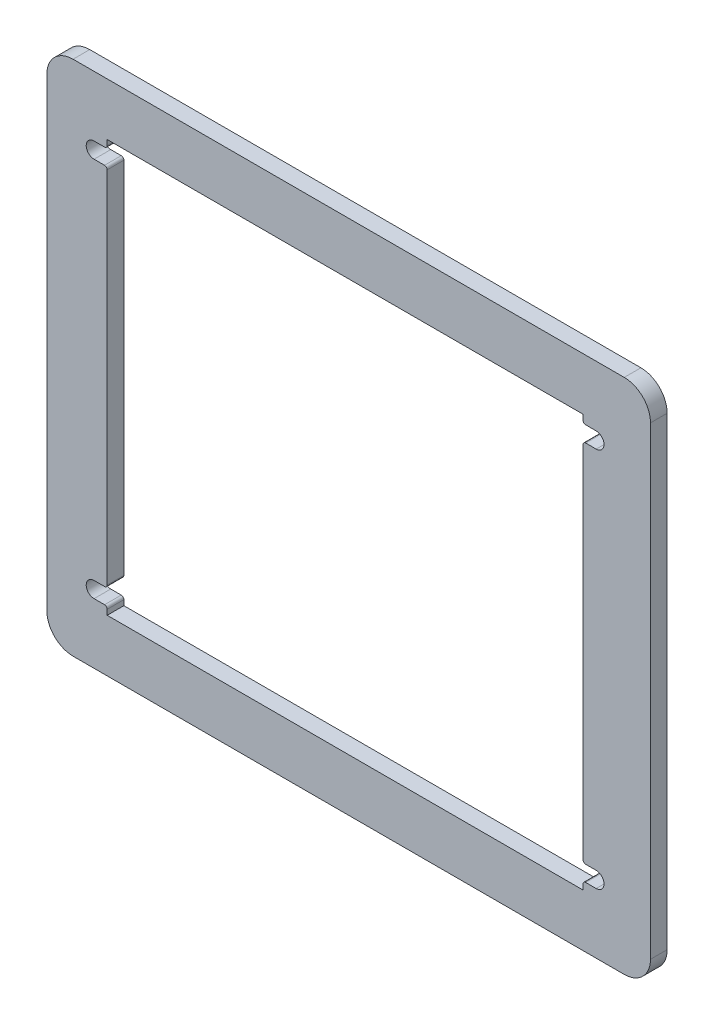
from build123d import *

# Parameters (mm, degrees)
BOSS_EXTRUDE1_DEPTH = 3.175


with BuildPart() as part:
    # Sketch2 → Boss-Extrude1 (new body)
    with BuildSketch(Plane.XY):
        with BuildLine():
            Line((-1, 10), (104, 10))
            ThreePointArc((104, 10), (107.535533906, 8.535533906), (109, 5))
            Line((109, 5), (109, -83.5))
            ThreePointArc((109, -83.5), (107.535533906, -87.035533906), (104, -88.5))
            Line((104, -88.5), (-1, -88.5))
            ThreePointArc((-1, -88.5), (-4.535533906, -87.035533906), (-6, -83.5))
            Line((-6, -83.5), (-6, 5))
            ThreePointArc((-6, 5), (-4.535533906, 8.535533906), (-1, 10))
        make_face()
        with BuildLine():
            Line((5.5, 0), (5.5, -1))
            ThreePointArc((5.5, -1), (5.353553391, -1.353553391), (5, -1.5))
            Line((5, -1.5), (3, -1.5))
            ThreePointArc((3, -1.5), (1.5, -3), (3, -4.5))
            Line((3, -4.5), (5, -4.5))
            ThreePointArc((5, -4.5), (5.353553391, -4.646446609), (5.5, -5))
            Line((5.5, -5), (5.5, -73.5))
            ThreePointArc((5.5, -73.5), (5.353553391, -73.853553391), (5, -74))
            Line((5, -74), (3, -74))
            ThreePointArc((3, -74), (1.5, -75.5), (3, -77))
            Line((3, -77), (5, -77))
            ThreePointArc((5, -77), (5.353553391, -77.146446609), (5.5, -77.5))
            Line((5.5, -77.5), (5.5, -78.5))
            Line((5.5, -78.5), (96.149180328, -78.5))
            Line((96.149180328, -78.5), (96.149180328, -77.5))
            ThreePointArc((96.149180328, -77.5), (96.295626937, -77.146446609), (96.649180328, -77))
            Line((96.649180328, -77), (98.649180328, -77))
            ThreePointArc((98.649180328, -77), (100.149180328, -75.5), (98.649180328, -74))
            Line((98.649180328, -74), (96.649180328, -74))
            ThreePointArc((96.649180328, -74), (96.295626937, -73.853553391), (96.149180328, -73.5))
            Line((96.149180328, -73.5), (96.149180328, -5))
            ThreePointArc((96.149180328, -5), (96.295626937, -4.646446609), (96.649180328, -4.5))
            Line((96.649180328, -4.5), (98.649180328, -4.5))
            ThreePointArc((98.649180328, -4.5), (100.149180328, -3), (98.649180328, -1.5))
            Line((98.649180328, -1.5), (96.649180328, -1.5))
            ThreePointArc((96.649180328, -1.5), (96.295626937, -1.353553391), (96.149180328, -1))
            Line((96.149180328, -1), (96.149180328, 0))
            Line((96.149180328, 0), (5.5, 0))
        make_face(mode=Mode.SUBTRACT)
    extrude(amount=BOSS_EXTRUDE1_DEPTH)


solid = part.part
